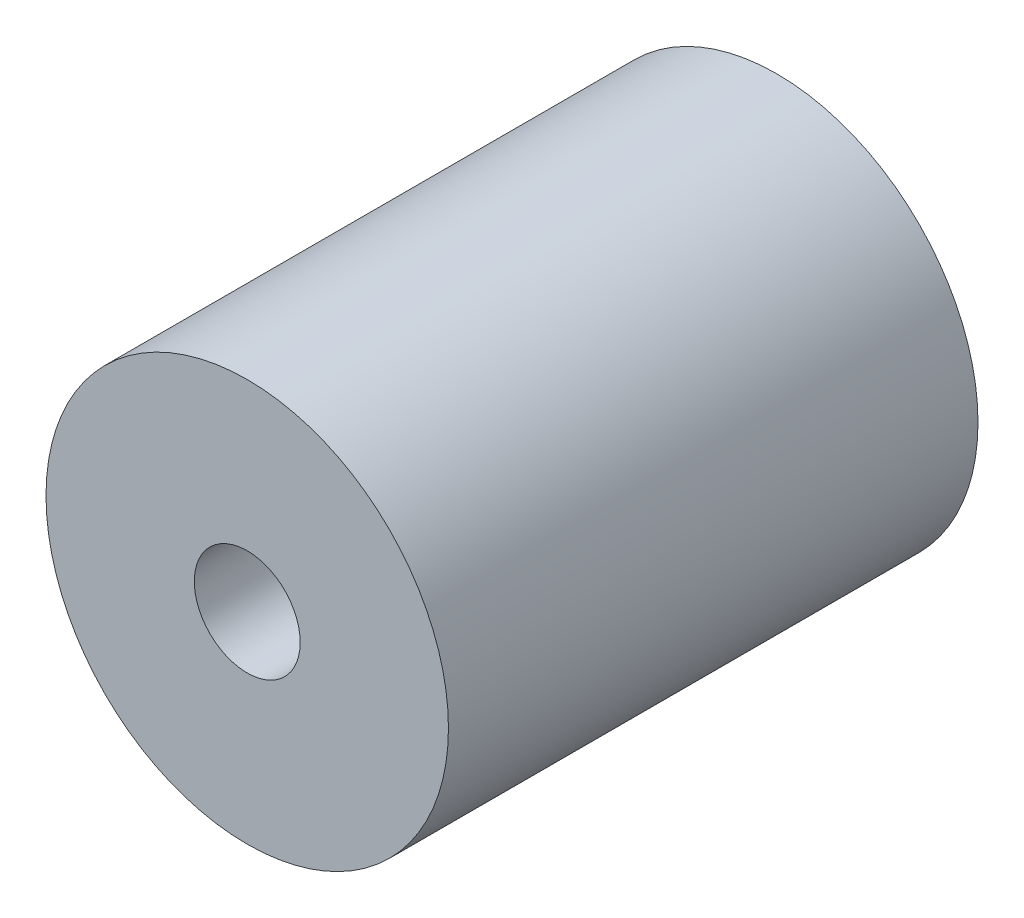
from build123d import *

# Parameters (mm, degrees)
SKETCH_2_R           = 9.5
EXTRUDE_1_DEPTH      = 12.5
SKETCH_4_OUTSIDE_W   = 28.34
SKETCH_4_OUTSIDE_H   = 28.34
SKETCH_4_OUTSIDE_R   = 9.5
SKETCH_4_OUTSIDE_R_2 = 4
CUT_EXTRUDE_1_DEPTH  = 12.5
SKETCH_5_OUTSIDE_W   = 28.34
SKETCH_5_OUTSIDE_H   = 28.34
SKETCH_5_OUTSIDE_R   = 9.5
SKETCH_5_OUTSIDE_R_2 = 2.5
CUT_EXTRUDE_2_DEPTH  = 12.5


with BuildPart() as part:
    # 草图2 → 凸台-拉伸1 (new body, symmetric)
    with BuildSketch(Plane.XY.offset(10)):
        with Locations((-14.788619837, 7.492683074)):
            Circle(SKETCH_2_R)
    extrude(amount=EXTRUDE_1_DEPTH, both=True)

    # 草图4 outside → 切除-拉伸1 (cut)
    with BuildSketch(Plane.XY.offset(10)):
        with Locations((-14.789, 7.493)):
            Rectangle(SKETCH_4_OUTSIDE_W, SKETCH_4_OUTSIDE_H)
        with Locations((-14.788619837, 7.492683074)):
            Circle(SKETCH_4_OUTSIDE_R, mode=Mode.SUBTRACT)
        with Locations((-14.788619837, 7.492683074)):
            Circle(SKETCH_4_OUTSIDE_R_2)
    extrude(amount=-CUT_EXTRUDE_1_DEPTH, mode=Mode.SUBTRACT)

    # 草图5 outside → 切除-拉伸2 (cut)
    with BuildSketch(Plane.XY.offset(10)):
        with Locations((-14.789, 7.493)):
            Rectangle(SKETCH_5_OUTSIDE_W, SKETCH_5_OUTSIDE_H)
        with Locations((-14.788619837, 7.492683074)):
            Circle(SKETCH_5_OUTSIDE_R, mode=Mode.SUBTRACT)
        with Locations((-14.788619837, 7.492683074)):
            Circle(SKETCH_5_OUTSIDE_R_2)
    extrude(amount=CUT_EXTRUDE_2_DEPTH, mode=Mode.SUBTRACT)


solid = part.part
